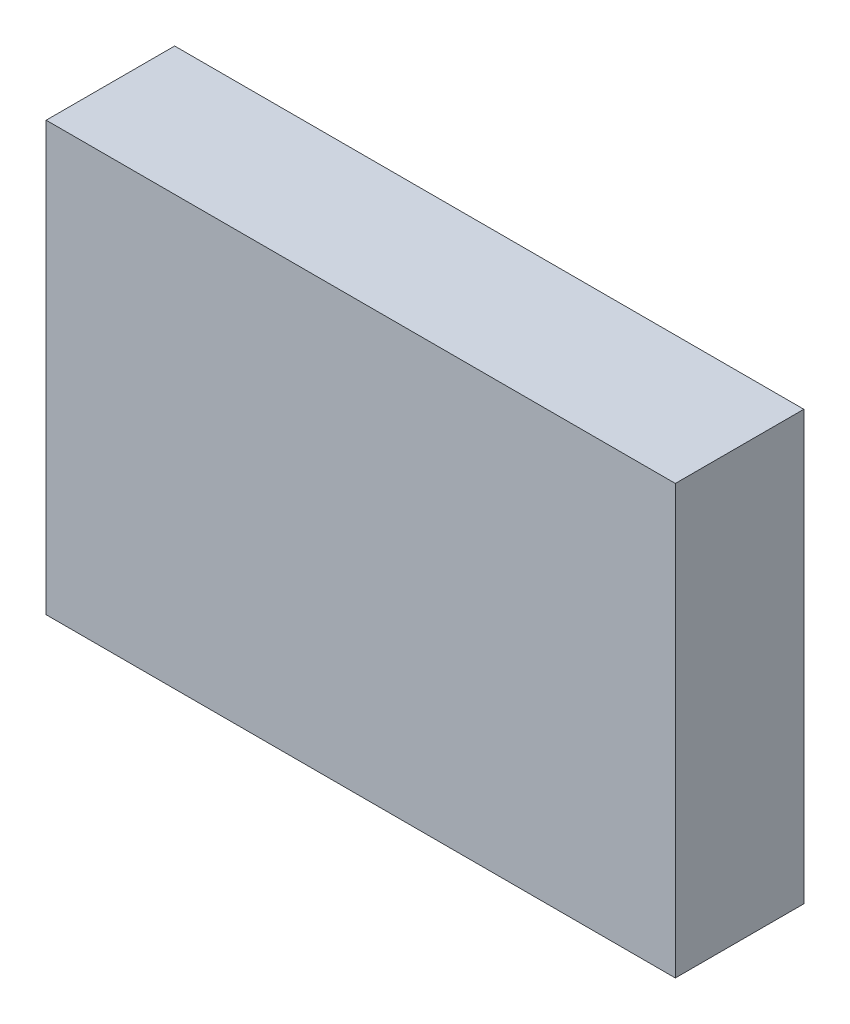
from build123d import *

# Parameters (mm, degrees)
ESQUISSE1_W        = 14.69
ESQUISSE1_H        = 10
BOSS_EXTRU_1_DEPTH = 3


with BuildPart() as part:
    # Esquisse1 → Boss.-Extru.1 (new body)
    with BuildSketch(Plane.XY):
        with Locations((-34.742389701, 18.836675127)):
            Rectangle(ESQUISSE1_W, ESQUISSE1_H)
    extrude(amount=BOSS_EXTRU_1_DEPTH)


solid = part.part
